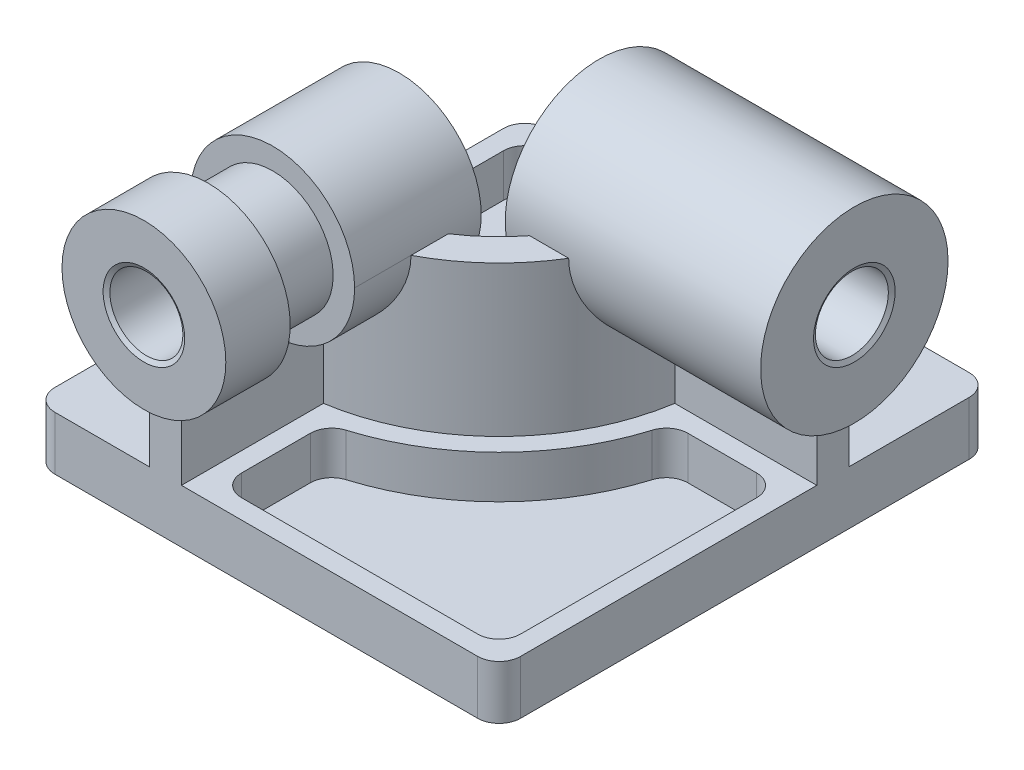
from build123d import *

# Parameters (mm, degrees)
SKETCH1_W             = 217
SKETCH1_H             = 229
BOSS_EXTRUDE1_DEPTH   = 25
EXTRUDE_THIN1_START   = -25
EXTRUDE_THIN1_DEPTH   = 95
FILLET1_R             = 10
CUT_EXTRUDE1_DEPTH    = 20
BOSS_EXTRUDE3_START   = 10
SKETCH10_R            = 38.166666667
BOSS_EXTRUDE3_DEPTH   = 119
SKETCH11_R            = 17
CUT_EXTRUDE2_DEPTH    = 119
BOSS_EXTRUDE4_START   = 10
SKETCH12_R            = 43.666666667
BOSS_EXTRUDE4_DEPTH   = 119
SKETCH13_R            = 17
CUT_EXTRUDE3_DEPTH    = 119
CHAMFER1_SIZE         = 2
CHAMFER1_SIZE2        = 1.154700538
CHAMFER1_PART_2_SIZE  = 2
CHAMFER1_PART_2_SIZE2 = 1.154700538
CHAMFER1_PART_3_SIZE  = 2
CHAMFER1_PART_3_SIZE2 = 1.154700538
CHAMFER1_PART_4_SIZE  = 2
CHAMFER1_PART_4_SIZE2 = 1.154700538
CUT_EXTRUDE4_DEPTH    = 20
CUT_EXTRUDE5_START    = -30
SKETCH16_R            = 38.166666667
SKETCH16_R_2          = 28.166666667
CUT_EXTRUDE5_DEPTH    = 30
BOSS_EXTRUDE5_REACH   = 115.667
SKETCH17_W            = 15
SKETCH17_H            = 30


with BuildPart() as part:
    # Sketch1 → Boss-Extrude1 (new body)
    with BuildSketch(Plane(origin=(0, 0, 0), x_dir=(1, 0, 0), z_dir=(0, 1, 0))):
        with Locations((-108.5, 114.5)):
            Rectangle(SKETCH1_W, SKETCH1_H)
    extrude(amount=BOSS_EXTRUDE1_DEPTH)

    # Sketch2 → Extrude-Thin1 (add)
    with BuildSketch(Plane(origin=(0, 25, 0), x_dir=(1, 0, 0), z_dir=(0, 1, 0)).offset(EXTRUDE_THIN1_START)):
        with BuildLine():
            Line((-163, 0), (-163, 80))
            ThreePointArc((-163, 80), (-104.310137162, 104.310137162), (-80, 163))
            Line((-80, 163), (0, 163))
            Line((0, 163), (0, 148))
            Line((0, 148), (-66.154762636, 148))
            ThreePointArc((-66.154762636, 148), (-93.703535444, 93.703535444), (-148, 66.154762636))
            Line((-148, 66.154762636), (-148, 0))
            Line((-148, 0), (-163, 0))
        make_face()
    extrude(amount=EXTRUDE_THIN1_DEPTH)

    # Fillet1
    fillet1_edges = [part.edges().sort_by_distance(p)[0] for p in [
        (0, 12.5, 0),
        (-217, 12.5, 0),
        (-217, 12.5, -229),
        (0, 12.5, -229),
    ]]
    fillet(fillet1_edges, radius=FILLET1_R)

    # Sketch9 → Cut-Extrude1 (cut)
    with BuildSketch(Plane(origin=(0, 25, 0), x_dir=(1, 0, 0), z_dir=(0, 1, 0))):
        with BuildLine():
            Line((-129, 9), (-19, 9))
            ThreePointArc((-19, 9), (-11.928932188, 11.928932188), (-9, 19))
            Line((-9, 19), (-9, 129))
            ThreePointArc((-9, 129), (-11.928932188, 136.071067812), (-19, 139))
            Line((-19, 139), (-51.049117913, 139))
            ThreePointArc((-51.049117913, 139), (-57.004794657, 137.033051383), (-60.617569374, 131.905982906))
            ThreePointArc((-60.617569374, 131.905982906), (-87.339574413, 87.339574413), (-131.905982906, 60.617569374))
            ThreePointArc((-131.905982906, 60.617569374), (-137.033051383, 57.004794657), (-139, 51.049117913))
            Line((-139, 51.049117913), (-139, 19))
            ThreePointArc((-139, 19), (-136.071067812, 11.928932188), (-129, 9))
        make_face()
    extrude(amount=-CUT_EXTRUDE1_DEPTH, mode=Mode.SUBTRACT)

    # Sketch10 → Boss-Extrude3 (add)
    with BuildSketch(Plane.XY.offset(BOSS_EXTRUDE3_START)):
        with Locations((-155.5, 95)):
            Circle(SKETCH10_R)
    extrude(amount=-BOSS_EXTRUDE3_DEPTH)

    # Sketch11 → Cut-Extrude2 (cut)
    with BuildSketch(Plane.XY.offset(10)):
        with Locations((-155.5, 95)):
            Circle(SKETCH11_R)
    extrude(amount=-CUT_EXTRUDE2_DEPTH, mode=Mode.SUBTRACT)

    # Sketch12 → Boss-Extrude4 (add)
    with BuildSketch(Plane(origin=(0, 0, 0), x_dir=(0, 0, -1), z_dir=(1, 0, 0)).offset(BOSS_EXTRUDE4_START)):
        with Locations((155.5, 95)):
            Circle(SKETCH12_R)
    extrude(amount=-BOSS_EXTRUDE4_DEPTH)

    # Sketch13 → Cut-Extrude3 (cut)
    with BuildSketch(Plane(origin=(10, 0, 0), x_dir=(0, 0, -1), z_dir=(1, 0, 0))):
        with Locations((155.5, 95)):
            Circle(SKETCH13_R)
    extrude(amount=-CUT_EXTRUDE3_DEPTH, mode=Mode.SUBTRACT)

    # Chamfer1
    chamfer1_edges = [part.edges().sort_by_distance(p)[0] for p in [
        (-172.5, 95, 10),
    ]]
    chamfer1_side = [part.faces().sort_by_distance(p)[0] for p in [
        (-192.587150314, 95, 10),
    ]]
    chamfer(chamfer1_edges, length=CHAMFER1_SIZE, length2=CHAMFER1_SIZE2, reference=chamfer1_side[0])

    # Chamfer1 part 2
    chamfer1_part_2_edges = [part.edges().sort_by_distance(p)[0] for p in [
        (-172.5, 95, -109),
    ]]
    chamfer1_part_2_side = [part.faces().sort_by_distance(p)[0] for p in [
        (-192.587150314, 95, -109),
    ]]
    chamfer(chamfer1_part_2_edges, length=CHAMFER1_PART_2_SIZE, length2=CHAMFER1_PART_2_SIZE2, reference=chamfer1_part_2_side[0])

    # Chamfer1 part 3
    chamfer1_part_3_edges = [part.edges().sort_by_distance(p)[0] for p in [
        (10, 95, -138.5),
    ]]
    chamfer1_part_3_side = [part.faces().sort_by_distance(p)[0] for p in [
        (10, 95, -113.068413178),
    ]]
    chamfer(chamfer1_part_3_edges, length=CHAMFER1_PART_3_SIZE, length2=CHAMFER1_PART_3_SIZE2, reference=chamfer1_part_3_side[0])

    # Chamfer1 part 4
    chamfer1_part_4_edges = [part.edges().sort_by_distance(p)[0] for p in [
        (-109, 95, -138.5),
    ]]
    chamfer1_part_4_side = [part.faces().sort_by_distance(p)[0] for p in [
        (-109, 95, -113.068413178),
    ]]
    chamfer(chamfer1_part_4_edges, length=CHAMFER1_PART_4_SIZE, length2=CHAMFER1_PART_4_SIZE2, reference=chamfer1_part_4_side[0])

    # Sketch15 → Cut-Extrude4 (cut)
    with BuildSketch(Plane(origin=(0, 25, 0), x_dir=(1, 0, 0), z_dir=(0, 1, 0))):
        with BuildLine():
            Line((-89, 163), (-89, 210))
            ThreePointArc((-89, 210), (-91.928932188, 217.071067812), (-99, 220))
            Line((-99, 220), (-198, 220))
            ThreePointArc((-198, 220), (-205.071067812, 217.071067812), (-208, 210))
            Line((-208, 210), (-208, 99))
            ThreePointArc((-208, 99), (-205.071067812, 91.928932188), (-198, 89))
            Line((-198, 89), (-163, 89))
            ThreePointArc((-163, 89), (-110.674098192, 110.674098192), (-89, 163))
        make_face()
    extrude(amount=-CUT_EXTRUDE4_DEPTH, mode=Mode.SUBTRACT)

    # Sketch16 → Cut-Extrude5 (cut)
    with BuildSketch(Plane.XY.offset(10).offset(CUT_EXTRUDE5_START)):
        with Locations((-155.5, 95)):
            Circle(SKETCH16_R)
        with Locations((-155.5, 95)):
            Circle(SKETCH16_R_2, mode=Mode.SUBTRACT)
    extrude(amount=-CUT_EXTRUDE5_DEPTH, mode=Mode.SUBTRACT)

    # Sketch17 → Boss-Extrude5 (add, up to next)
    with BuildSketch(Plane(origin=(0, 25, 0), x_dir=(1, 0, 0), z_dir=(0, 1, 0)), mode=Mode.PRIVATE) as boss_extrude5_sk1:
        with Locations((-155.5, 35)):
            Rectangle(SKETCH17_W, SKETCH17_H)
    boss_extrude5_tool1 = extrude(boss_extrude5_sk1.sketch, amount=BOSS_EXTRUDE5_REACH, mode=Mode.PRIVATE) - part.part
    add(boss_extrude5_tool1.solids().sort_by_distance((-155.5, 25, -35))[0])


solid = part.part
